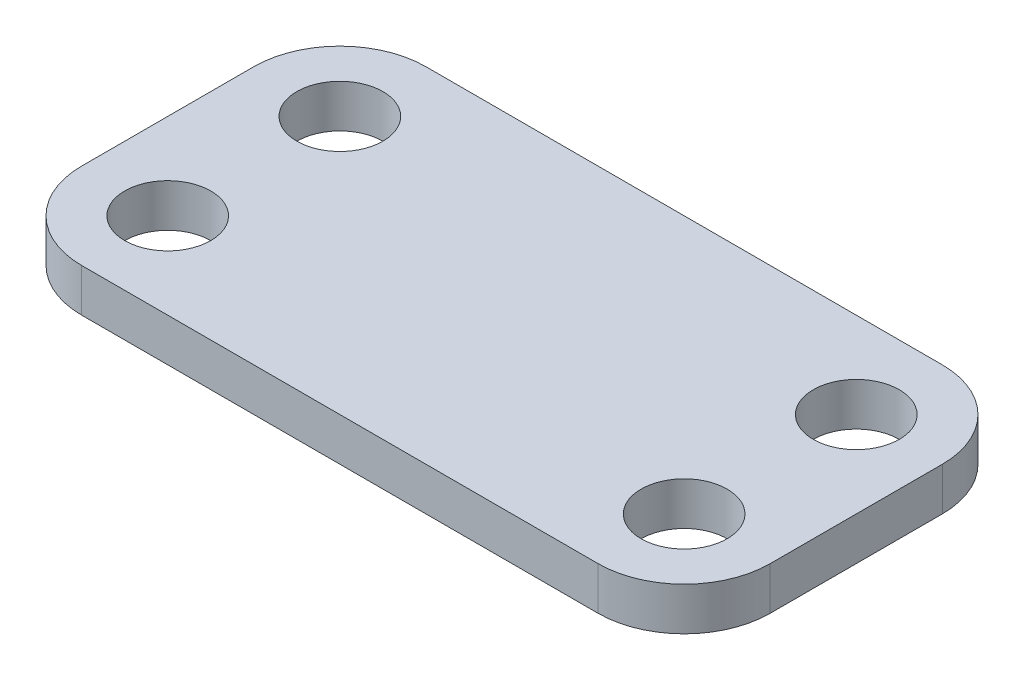
from build123d import *

# Parameters (mm, degrees)
SKETCH2_R           = 3.175
BOSS_EXTRUDE1_DEPTH = 3.175


with BuildPart() as part:
    # Sketch2 → Boss-Extrude1 (new body)
    with BuildSketch(Plane(origin=(0, 0, 0), x_dir=(1, 0, 0), z_dir=(0, 1, 0))):
        with BuildLine():
            Line((-19.05, -12.7), (19.05, -12.7))
            ThreePointArc((19.05, -12.7), (23.540128061, -10.840128061), (25.4, -6.35))
            Line((25.4, -6.35), (25.4, 6.35))
            ThreePointArc((25.4, 6.35), (23.540128061, 10.840128061), (19.05, 12.7))
            Line((19.05, 12.7), (-19.05, 12.7))
            ThreePointArc((-19.05, 12.7), (-23.540128061, 10.840128061), (-25.4, 6.35))
            Line((-25.4, 6.35), (-25.4, -6.35))
            ThreePointArc((-25.4, -6.35), (-23.540128061, -10.840128061), (-19.05, -12.7))
        make_face()
        with Locations((-19.05, 6.35)):
            Circle(SKETCH2_R, mode=Mode.SUBTRACT)
        with Locations((-19.05, -6.35)):
            Circle(SKETCH2_R, mode=Mode.SUBTRACT)
        with Locations((19.05, 6.35)):
            Circle(SKETCH2_R, mode=Mode.SUBTRACT)
        with Locations((19.05, -6.35)):
            Circle(SKETCH2_R, mode=Mode.SUBTRACT)
    extrude(amount=BOSS_EXTRUDE1_DEPTH)


solid = part.part
